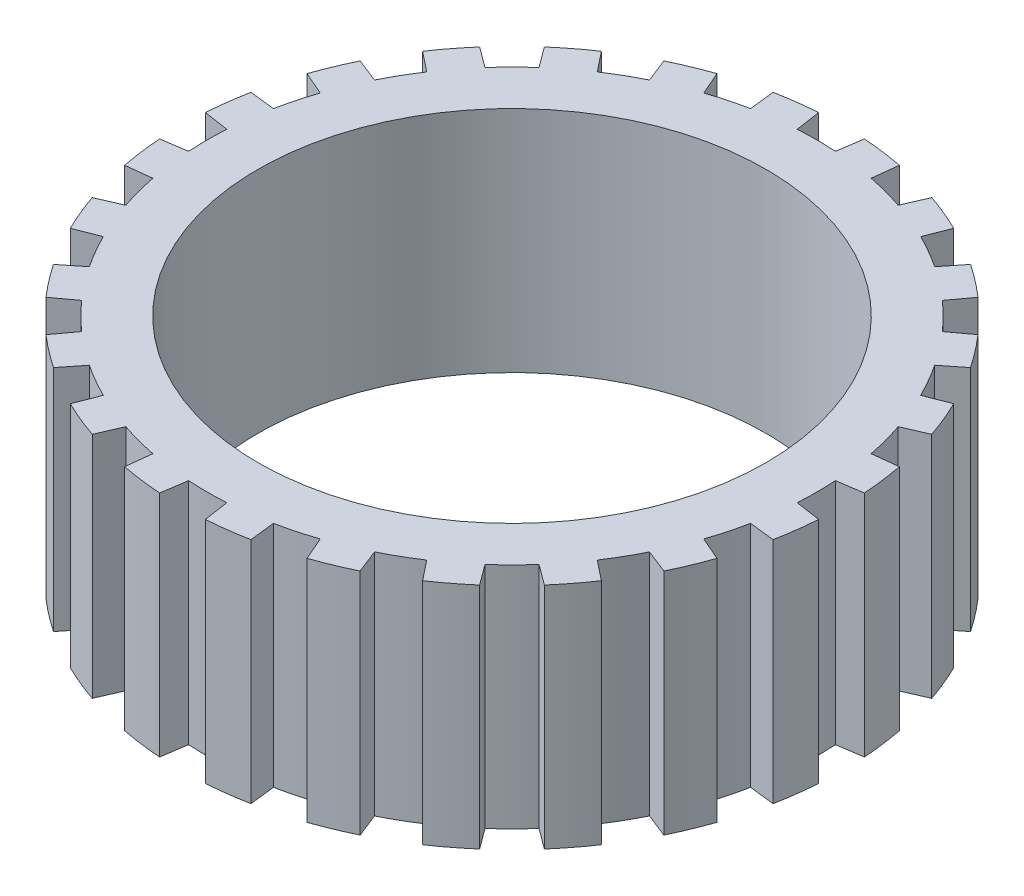
from build123d import *

# Parameters (mm, degrees)
SKETCH2_W           = 10
SKETCH2_H           = 45
BOSS_EXTRUDE1_DEPTH = 45


with BuildPart() as part:
    # Sketch2 → Revolve1 (revolve)
    with BuildSketch(Plane.XY):
        with Locations((55, 22.5)):
            Rectangle(SKETCH2_W, SKETCH2_H)
    revolve(axis=Axis((0, -1000, 0), (0, 1, 0)))

    # Sketch3 → Boss-Extrude1 (add)
    with BuildSketch(Plane(origin=(0, 0, 0), x_dir=(1, 0, 0), z_dir=(0, 1, 0))):
        with BuildLine():
            Line((4.502343049, 64.84388103), (3.76078814, 59.88202128))
            ThreePointArc((3.76078814, 59.88202128), (7.831571533, 59.486691682), (11.865965175, 58.81495448))
            Line((11.865965175, 58.81495448), (12.43390194, 63.799671493))
            ThreePointArc((12.43390194, 63.799671493), (8.484202494, 64.443915989), (4.502343049, 64.84388103))
        make_face()
        with BuildLine():
            Line((21.131760798, 61.469087235), (19.131249958, 56.868227289))
            ThreePointArc((19.131249958, 56.868227289), (22.961005942, 55.432771951), (26.684072572, 53.739745728))
            Line((26.684072572, 53.739745728), (28.522797059, 58.407619777))
            ThreePointArc((28.522797059, 58.407619777), (24.874423104, 60.052169613), (21.131760798, 61.469087235))
        make_face()
        with BuildLine():
            Line((36.321083972, 53.905276728), (33.197948708, 49.978957588))
            ThreePointArc((33.197948708, 49.978957588), (36.525685741, 47.601200417), (39.683704522, 45.002262115))
            Line((39.683704522, 45.002262115), (42.667910694, 49.035185296))
            ThreePointArc((42.667910694, 49.035185296), (39.569492886, 51.567967119), (36.321083972, 53.905276728))
        make_face()
        with BuildLine():
            Line((49.035185296, 42.667910694), (45.002262115, 39.683704522))
            ThreePointArc((45.002262115, 39.683704522), (47.601200417, 36.525685741), (49.978957588, 33.197948708))
            Line((49.978957588, 33.197948708), (53.905276728, 36.321083972))
            ThreePointArc((53.905276728, 36.321083972), (51.567967119, 39.569492886), (49.035185296, 42.667910694))
        make_face()
        with BuildLine():
            Line((58.407619777, 28.522797059), (53.739745728, 26.684072572))
            ThreePointArc((53.739745728, 26.684072572), (55.432771951, 22.961005942), (56.868227289, 19.131249958))
            Line((56.868227289, 19.131249958), (61.469087235, 21.131760798))
            ThreePointArc((61.469087235, 21.131760798), (60.052169613, 24.874423104), (58.407619777, 28.522797059))
        make_face()
        with BuildLine():
            Line((63.799671493, 12.43390194), (58.81495448, 11.865965175))
            ThreePointArc((58.81495448, 11.865965175), (59.486691682, 7.831571533), (59.88202128, 3.76078814))
            Line((59.88202128, 3.76078814), (64.84388103, 4.502343049))
            ThreePointArc((64.84388103, 4.502343049), (64.443915989, 8.484202494), (63.799671493, 12.43390194))
        make_face()
        with BuildLine():
            Line((64.84388103, -4.502343049), (59.88202128, -3.76078814))
            ThreePointArc((59.88202128, -3.76078814), (59.486691682, -7.831571533), (58.81495448, -11.865965175))
            Line((58.81495448, -11.865965175), (63.799671493, -12.43390194))
            ThreePointArc((63.799671493, -12.43390194), (64.443915989, -8.484202494), (64.84388103, -4.502343049))
        make_face()
        with BuildLine():
            Line((61.469087235, -21.131760798), (56.868227289, -19.131249958))
            ThreePointArc((56.868227289, -19.131249958), (55.432771951, -22.961005942), (53.739745728, -26.684072572))
            Line((53.739745728, -26.684072572), (58.407619777, -28.522797059))
            ThreePointArc((58.407619777, -28.522797059), (60.052169613, -24.874423104), (61.469087235, -21.131760798))
        make_face()
        with BuildLine():
            Line((53.905276728, -36.321083972), (49.978957588, -33.197948708))
            ThreePointArc((49.978957588, -33.197948708), (47.601200417, -36.525685741), (45.002262115, -39.683704522))
            Line((45.002262115, -39.683704522), (49.035185296, -42.667910694))
            ThreePointArc((49.035185296, -42.667910694), (51.567967119, -39.569492886), (53.905276728, -36.321083972))
        make_face()
        with BuildLine():
            Line((42.667910694, -49.035185296), (39.683704522, -45.002262115))
            ThreePointArc((39.683704522, -45.002262115), (36.525685741, -47.601200417), (33.197948708, -49.978957588))
            Line((33.197948708, -49.978957588), (36.321083972, -53.905276728))
            ThreePointArc((36.321083972, -53.905276728), (39.569492886, -51.567967119), (42.667910694, -49.035185296))
        make_face()
        with BuildLine():
            Line((28.522797059, -58.407619777), (26.684072572, -53.739745728))
            ThreePointArc((26.684072572, -53.739745728), (22.961005942, -55.432771951), (19.131249958, -56.868227289))
            Line((19.131249958, -56.868227289), (21.131760798, -61.469087235))
            ThreePointArc((21.131760798, -61.469087235), (24.874423104, -60.052169613), (28.522797059, -58.407619777))
        make_face()
        with BuildLine():
            Line((12.43390194, -63.799671493), (11.865965175, -58.81495448))
            ThreePointArc((11.865965175, -58.81495448), (7.831571533, -59.486691682), (3.76078814, -59.88202128))
            Line((3.76078814, -59.88202128), (4.502343049, -64.84388103))
            ThreePointArc((4.502343049, -64.84388103), (8.484202494, -64.443915989), (12.43390194, -63.799671493))
        make_face()
        with BuildLine():
            Line((-4.502343049, -64.84388103), (-3.76078814, -59.88202128))
            ThreePointArc((-3.76078814, -59.88202128), (-7.831571533, -59.486691682), (-11.865965175, -58.81495448))
            Line((-11.865965175, -58.81495448), (-12.43390194, -63.799671493))
            ThreePointArc((-12.43390194, -63.799671493), (-8.484202494, -64.443915989), (-4.502343049, -64.84388103))
        make_face()
        with BuildLine():
            Line((-21.131760798, -61.469087235), (-19.131249958, -56.868227289))
            ThreePointArc((-19.131249958, -56.868227289), (-22.961005942, -55.432771951), (-26.684072572, -53.739745728))
            Line((-26.684072572, -53.739745728), (-28.522797059, -58.407619777))
            ThreePointArc((-28.522797059, -58.407619777), (-24.874423104, -60.052169613), (-21.131760798, -61.469087235))
        make_face()
        with BuildLine():
            Line((-36.321083972, -53.905276728), (-33.197948708, -49.978957588))
            ThreePointArc((-33.197948708, -49.978957588), (-36.525685741, -47.601200417), (-39.683704522, -45.002262115))
            Line((-39.683704522, -45.002262115), (-42.667910694, -49.035185296))
            ThreePointArc((-42.667910694, -49.035185296), (-39.569492886, -51.567967119), (-36.321083972, -53.905276728))
        make_face()
        with BuildLine():
            Line((-49.035185296, -42.667910694), (-45.002262115, -39.683704522))
            ThreePointArc((-45.002262115, -39.683704522), (-47.601200417, -36.525685741), (-49.978957588, -33.197948708))
            Line((-49.978957588, -33.197948708), (-53.905276728, -36.321083972))
            ThreePointArc((-53.905276728, -36.321083972), (-51.567967119, -39.569492886), (-49.035185296, -42.667910694))
        make_face()
        with BuildLine():
            Line((-58.407619777, -28.522797059), (-53.739745728, -26.684072572))
            ThreePointArc((-53.739745728, -26.684072572), (-55.432771951, -22.961005942), (-56.868227289, -19.131249958))
            Line((-56.868227289, -19.131249958), (-61.469087235, -21.131760798))
            ThreePointArc((-61.469087235, -21.131760798), (-60.052169613, -24.874423104), (-58.407619777, -28.522797059))
        make_face()
        with BuildLine():
            Line((-63.799671493, -12.43390194), (-58.81495448, -11.865965175))
            ThreePointArc((-58.81495448, -11.865965175), (-59.486691682, -7.831571533), (-59.88202128, -3.76078814))
            Line((-59.88202128, -3.76078814), (-64.84388103, -4.502343049))
            ThreePointArc((-64.84388103, -4.502343049), (-64.443915989, -8.484202494), (-63.799671493, -12.43390194))
        make_face()
        with BuildLine():
            Line((-64.84388103, 4.502343049), (-59.88202128, 3.76078814))
            ThreePointArc((-59.88202128, 3.76078814), (-59.486691682, 7.831571533), (-58.81495448, 11.865965175))
            Line((-58.81495448, 11.865965175), (-63.799671493, 12.43390194))
            ThreePointArc((-63.799671493, 12.43390194), (-64.443915989, 8.484202494), (-64.84388103, 4.502343049))
        make_face()
        with BuildLine():
            Line((-61.469087235, 21.131760798), (-56.868227289, 19.131249958))
            ThreePointArc((-56.868227289, 19.131249958), (-55.432771951, 22.961005942), (-53.739745728, 26.684072572))
            Line((-53.739745728, 26.684072572), (-58.407619777, 28.522797059))
            ThreePointArc((-58.407619777, 28.522797059), (-60.052169613, 24.874423104), (-61.469087235, 21.131760798))
        make_face()
        with BuildLine():
            Line((-53.905276728, 36.321083972), (-49.978957588, 33.197948708))
            ThreePointArc((-49.978957588, 33.197948708), (-47.601200417, 36.525685741), (-45.002262115, 39.683704522))
            Line((-45.002262115, 39.683704522), (-49.035185296, 42.667910694))
            ThreePointArc((-49.035185296, 42.667910694), (-51.567967119, 39.569492886), (-53.905276728, 36.321083972))
        make_face()
        with BuildLine():
            Line((-42.667910694, 49.035185296), (-39.683704522, 45.002262115))
            ThreePointArc((-39.683704522, 45.002262115), (-36.525685741, 47.601200417), (-33.197948708, 49.978957588))
            Line((-33.197948708, 49.978957588), (-36.321083972, 53.905276728))
            ThreePointArc((-36.321083972, 53.905276728), (-39.569492886, 51.567967119), (-42.667910694, 49.035185296))
        make_face()
        with BuildLine():
            Line((-28.522797059, 58.407619777), (-26.684072572, 53.739745728))
            ThreePointArc((-26.684072572, 53.739745728), (-22.961005942, 55.432771951), (-19.131249958, 56.868227289))
            Line((-19.131249958, 56.868227289), (-21.131760798, 61.469087235))
            ThreePointArc((-21.131760798, 61.469087235), (-24.874423104, 60.052169613), (-28.522797059, 58.407619777))
        make_face()
        with BuildLine():
            Line((-12.43390194, 63.799671493), (-11.865965175, 58.81495448))
            ThreePointArc((-11.865965175, 58.81495448), (-7.831571533, 59.486691682), (-3.76078814, 59.88202128))
            Line((-3.76078814, 59.88202128), (-4.502343049, 64.84388103))
            ThreePointArc((-4.502343049, 64.84388103), (-8.484202494, 64.443915989), (-12.43390194, 63.799671493))
        make_face()
    extrude(amount=BOSS_EXTRUDE1_DEPTH)


solid = part.part
